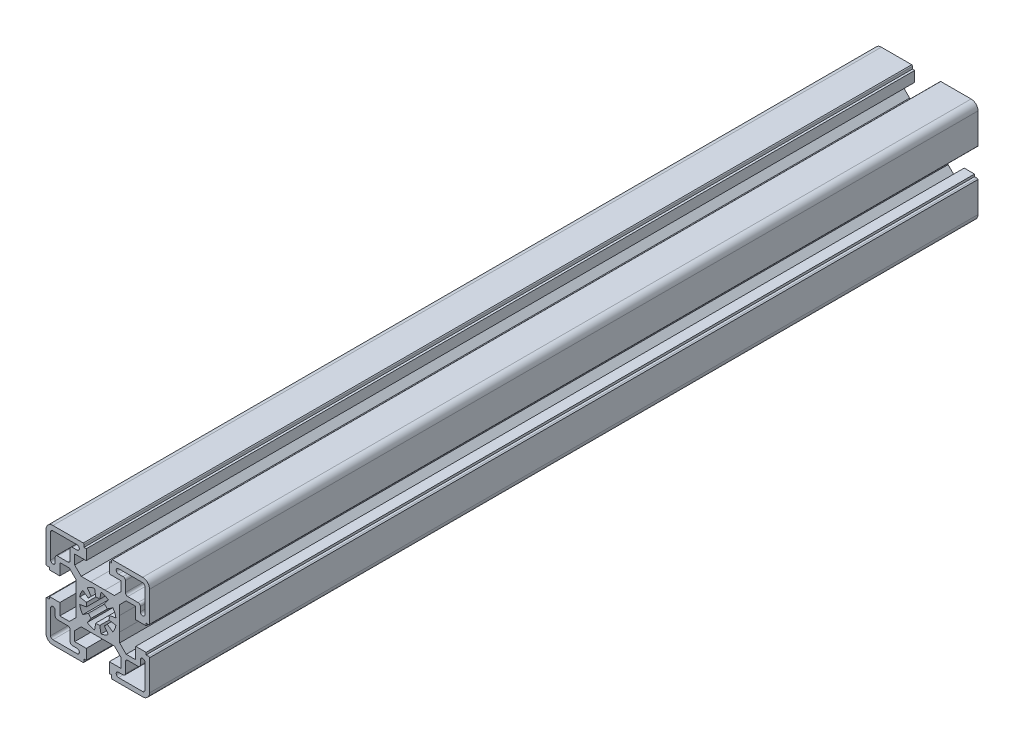
from build123d import *

# Parameters (mm, degrees)
BOSS_EXTRUDE1_DEPTH = 360


with BuildPart() as part:
    # Sketch1 → Boss-Extrude1 (new body)
    with BuildSketch(Plane.XY):
        with BuildLine():
            Line((-9.499953806, 3.122740916), (-9.499953806, 7.206970084))
            Line((-9.499953806, 7.206970084), (-12.342923806, 10.049940084))
            Line((-12.342923806, 10.049940084), (-16.500012806, 10.049940084))
            Line((-16.500012806, 10.049940084), (-16.500012806, 4.999940084))
            Line((-16.500012806, 4.999940084), (-20.999920806, 4.999940084))
            Line((-20.999920806, 4.999940084), (-20.999920806, 6))
            Line((-20.999920806, 6), (-21.99992119, 6))
            ThreePointArc((-21.99992119, 6), (-22.298164639, 6.069539801), (-22.49992067, 6.299929564))
            Line((-22.49992067, 6.299929564), (-22.49992067, 19.500002241))
            ThreePointArc((-22.49992067, 19.500002241), (-21.62124167, 21.621321), (-19.499922911, 22.5))
            Line((-19.499922911, 22.5), (-6.299954884, 22.5))
            ThreePointArc((-6.299954884, 22.5), (-6.069541349, 22.298205758), (-6, 21.999918456))
            Line((-6, 21.999918456), (-6, 20.999918083))
            Line((-6, 20.999918083), (-5, 20.999918083))
            Line((-5, 20.999918083), (-5, 16.499959846))
            Line((-5, 16.499959846), (-10.050086009, 16.499959846))
            Line((-10.050086009, 16.499959846), (-10.050086009, 12.342824291))
            Line((-10.050086009, 12.342824291), (-7.207137036, 9.499875319))
            Line((-7.207137036, 9.499875319), (-3.122784036, 9.499875319))
            Line((-3.122784036, 9.499875319), (3.122740916, 9.499953806))
            Line((3.122740916, 9.499953806), (7.206970084, 9.499953806))
            Line((7.206970084, 9.499953806), (10.049940084, 12.342923806))
            Line((10.049940084, 12.342923806), (10.049940084, 16.500012806))
            Line((10.049940084, 16.500012806), (4.999940084, 16.500012806))
            Line((4.999940084, 16.500012806), (4.999940084, 20.999920806))
            Line((4.999940084, 20.999920806), (6, 20.999920806))
            Line((6, 20.999920806), (6, 21.99992119))
            ThreePointArc((6, 21.99992119), (6.069539801, 22.298164639), (6.299929564, 22.49992067))
            Line((6.299929564, 22.49992067), (19.500002241, 22.49992067))
            ThreePointArc((19.500002241, 22.49992067), (21.621321, 21.62124167), (22.5, 19.499922911))
            Line((22.5, 19.499922911), (22.5, 6.299954884))
            ThreePointArc((22.5, 6.299954884), (22.298205758, 6.069541349), (21.999918456, 6))
            Line((21.999918456, 6), (20.999918083, 6))
            Line((20.999918083, 6), (20.999918083, 5))
            Line((20.999918083, 5), (16.499959846, 5))
            Line((16.499959846, 5), (16.499959846, 10.050086009))
            Line((16.499959846, 10.050086009), (12.342824291, 10.050086009))
            Line((12.342824291, 10.050086009), (9.499875319, 7.207137036))
            Line((9.499875319, 7.207137036), (9.499875319, 3.122784036))
            Line((9.499875319, 3.122784036), (9.499953806, -3.122740916))
            Line((9.499953806, -3.122740916), (9.499953806, -7.206970084))
            Line((9.499953806, -7.206970084), (12.342923806, -10.049940084))
            Line((12.342923806, -10.049940084), (16.500012806, -10.049940084))
            Line((16.500012806, -10.049940084), (16.500012806, -4.999940084))
            Line((16.500012806, -4.999940084), (20.999920806, -4.999940084))
            Line((20.999920806, -4.999940084), (20.999920806, -6))
            Line((20.999920806, -6), (21.99992119, -6))
            ThreePointArc((21.99992119, -6), (22.298164639, -6.069539801), (22.49992067, -6.299929564))
            Line((22.49992067, -6.299929564), (22.49992067, -19.500002241))
            ThreePointArc((22.49992067, -19.500002241), (21.62124167, -21.621321), (19.499922911, -22.5))
            Line((19.499922911, -22.5), (6.299954884, -22.5))
            ThreePointArc((6.299954884, -22.5), (6.069541349, -22.298205758), (6, -21.999918456))
            Line((6, -21.999918456), (6, -20.999918083))
            Line((6, -20.999918083), (5, -20.999918083))
            Line((5, -20.999918083), (5, -16.499959846))
            Line((5, -16.499959846), (10.050086009, -16.499959846))
            Line((10.050086009, -16.499959846), (10.050086009, -12.342824291))
            Line((10.050086009, -12.342824291), (7.207137036, -9.499875319))
            Line((7.207137036, -9.499875319), (3.122784036, -9.499875319))
            Line((3.122784036, -9.499875319), (-3.122740916, -9.499953806))
            Line((-3.122740916, -9.499953806), (-7.206970084, -9.499953806))
            Line((-7.206970084, -9.499953806), (-10.049940084, -12.342923806))
            Line((-10.049940084, -12.342923806), (-10.049940084, -16.500012806))
            Line((-10.049940084, -16.500012806), (-4.999940084, -16.500012806))
            Line((-4.999940084, -16.500012806), (-4.999940084, -20.999920806))
            Line((-4.999940084, -20.999920806), (-6, -20.999920806))
            Line((-6, -20.999920806), (-6, -21.99992119))
            ThreePointArc((-6, -21.99992119), (-6.069539801, -22.298164639), (-6.299929564, -22.49992067))
            Line((-6.299929564, -22.49992067), (-19.500002241, -22.49992067))
            ThreePointArc((-19.500002241, -22.49992067), (-21.621321, -21.62124167), (-22.5, -19.499922911))
            Line((-22.5, -19.499922911), (-22.5, -6.299954884))
            ThreePointArc((-22.5, -6.299954884), (-22.298205758, -6.069541349), (-21.999918456, -6))
            Line((-21.999918456, -6), (-20.999918083, -6))
            Line((-20.999918083, -6), (-20.999918083, -5))
            Line((-20.999918083, -5), (-16.499959846, -5))
            Line((-16.499959846, -5), (-16.499959846, -10.050086009))
            Line((-16.499959846, -10.050086009), (-12.342824291, -10.050086009))
            Line((-12.342824291, -10.050086009), (-9.499875319, -7.207137036))
            Line((-9.499875319, -7.207137036), (-9.499875319, -3.122784036))
            Line((-9.499875319, -3.122784036), (-9.499953806, 3.122740916))
        make_face()
        with BuildLine():
            Line((-4.588627311, 6.553189057), (-2.867885877, 4.095734317))
            ThreePointArc((-2.867885877, 4.095734317), (-3.535525782, 3.535515019), (-4.095743048, 2.867873408))
            Line((-4.095743048, 2.867873408), (-6.553203027, 4.588607361))
            ThreePointArc((-6.553203027, 4.588607361), (-7.391023494, 3.061463561), (-7.878449234, 1.389181447))
            Line((-7.878449234, 1.389181447), (-4.924020139, 0.868236529))
            ThreePointArc((-4.924020139, 0.868236529), (-4.9999809, 6.442e-06), (-4.924022376, -0.868223842))
            Line((-4.924022376, -0.868223842), (-7.878452813, -1.389161146))
            ThreePointArc((-7.878452813, -1.389161146), (-7.391022778, -3.061465289), (-6.553189057, -4.588627311))
            Line((-6.553189057, -4.588627311), (-4.095734317, -2.867885877))
            ThreePointArc((-4.095734317, -2.867885877), (-3.535515019, -3.535525782), (-2.867873408, -4.095743048))
            Line((-2.867873408, -4.095743048), (-4.588607361, -6.553203027))
            ThreePointArc((-4.588607361, -6.553203027), (-3.061463561, -7.391023494), (-1.389181447, -7.878449234))
            Line((-1.389181447, -7.878449234), (-0.868236529, -4.924020139))
            ThreePointArc((-0.868236529, -4.924020139), (-6.442e-06, -4.9999809), (0.868223842, -4.924022376))
            Line((0.868223842, -4.924022376), (1.389161146, -7.878452813))
            ThreePointArc((1.389161146, -7.878452813), (3.061465289, -7.391022778), (4.588627311, -6.553189057))
            Line((4.588627311, -6.553189057), (2.867885877, -4.095734317))
            ThreePointArc((2.867885877, -4.095734317), (3.535525782, -3.535515019), (4.095743048, -2.867873408))
            Line((4.095743048, -2.867873408), (6.553203027, -4.588607361))
            ThreePointArc((6.553203027, -4.588607361), (7.391023494, -3.061463561), (7.878449234, -1.389181447))
            Line((7.878449234, -1.389181447), (4.924020139, -0.868236529))
            ThreePointArc((4.924020139, -0.868236529), (4.9999809, -6.442e-06), (4.924022376, 0.868223842))
            Line((4.924022376, 0.868223842), (7.878452813, 1.389161146))
            ThreePointArc((7.878452813, 1.389161146), (7.391022778, 3.061465289), (6.553189057, 4.588627311))
            Line((6.553189057, 4.588627311), (4.095734317, 2.867885877))
            ThreePointArc((4.095734317, 2.867885877), (3.535515019, 3.535525782), (2.867873408, 4.095743048))
            Line((2.867873408, 4.095743048), (4.588607361, 6.553203027))
            ThreePointArc((4.588607361, 6.553203027), (3.061463561, 7.391023494), (1.389181447, 7.878449234))
            Line((1.389181447, 7.878449234), (0.868236529, 4.924020139))
            ThreePointArc((0.868236529, 4.924020139), (6.442e-06, 4.9999809), (-0.868223842, 4.924022376))
            Line((-0.868223842, 4.924022376), (-1.389161146, 7.878452813))
            ThreePointArc((-1.389161146, 7.878452813), (-3.061465289, 7.391022778), (-4.588627311, 6.553189057))
        make_face(mode=Mode.SUBTRACT)
        with BuildLine():
            Line((-17.500118733, 12.000017917), (-13.000117238, 12.000017917))
            ThreePointArc((-13.000117238, 12.000017917), (-12.293010986, 12.292910917), (-12.000117986, 13.00001717))
            Line((-12.000117986, 13.00001717), (-12.000117986, 17.49992083))
            ThreePointArc((-12.000117986, 17.49992083), (-11.707224986, 18.207027083), (-11.000118733, 18.499920083))
            Line((-11.000118733, 18.499920083), (-9.000117986, 18.499920083))
            ThreePointArc((-9.000117986, 18.499920083), (-8.000069069, 19.499969), (-9.000117986, 20.500017917))
            Line((-9.000117986, 20.500017917), (-19.500118733, 20.500017917))
            ThreePointArc((-19.500118733, 20.500017917), (-20.207224985, 20.207124917), (-20.500117986, 19.500018664))
            Line((-20.500117986, 19.500018664), (-20.500117986, 8.999920083))
            ThreePointArc((-20.500117986, 8.999920083), (-19.500117986, 7.999920083), (-18.500117985, 8.999920083))
            Line((-18.500117985, 8.999920083), (-18.500117985, 11.000018664))
            ThreePointArc((-18.500117985, 11.000018664), (-18.207224985, 11.707124917), (-17.500118733, 12.000017917))
        make_face(mode=Mode.SUBTRACT)
        with BuildLine():
            Line((12.000017917, 17.500118733), (12.000017917, 13.000117238))
            ThreePointArc((12.000017917, 13.000117238), (12.292910917, 12.293010986), (13.00001717, 12.000117986))
            Line((13.00001717, 12.000117986), (17.49992083, 12.000117986))
            ThreePointArc((17.49992083, 12.000117986), (18.207027083, 11.707224986), (18.499920083, 11.000118733))
            Line((18.499920083, 11.000118733), (18.499920083, 9.000117986))
            ThreePointArc((18.499920083, 9.000117986), (19.499969, 8.000069069), (20.500017917, 9.000117986))
            Line((20.500017917, 9.000117986), (20.500017917, 19.500118733))
            ThreePointArc((20.500017917, 19.500118733), (20.207124917, 20.207224985), (19.500018664, 20.500117985))
            Line((19.500018664, 20.500117985), (8.999920083, 20.500117985))
            ThreePointArc((8.999920083, 20.500117985), (7.999920083, 19.500117985), (8.999920083, 18.500117985))
            Line((8.999920083, 18.500117985), (11.000018664, 18.500117985))
            ThreePointArc((11.000018664, 18.500117985), (11.707124917, 18.207224985), (12.000017917, 17.500118733))
        make_face(mode=Mode.SUBTRACT)
        with BuildLine():
            Line((17.500118733, -12.000017917), (13.000117238, -12.000017917))
            ThreePointArc((13.000117238, -12.000017917), (12.293010986, -12.292910917), (12.000117986, -13.00001717))
            Line((12.000117986, -13.00001717), (12.000117986, -17.49992083))
            ThreePointArc((12.000117986, -17.49992083), (11.707224986, -18.207027083), (11.000118733, -18.499920083))
            Line((11.000118733, -18.499920083), (9.000117986, -18.499920083))
            ThreePointArc((9.000117986, -18.499920083), (8.000069069, -19.499969), (9.000117986, -20.500017917))
            Line((9.000117986, -20.500017917), (19.500118733, -20.500017917))
            ThreePointArc((19.500118733, -20.500017917), (20.207224985, -20.207124917), (20.500117985, -19.500018664))
            Line((20.500117985, -19.500018664), (20.500117985, -8.999920083))
            ThreePointArc((20.500117985, -8.999920083), (19.500117985, -7.999920083), (18.500117985, -8.999920083))
            Line((18.500117985, -8.999920083), (18.500117985, -11.000018664))
            ThreePointArc((18.500117985, -11.000018664), (18.207224985, -11.707124917), (17.500118733, -12.000017917))
        make_face(mode=Mode.SUBTRACT)
        with BuildLine():
            Line((-12.000017917, -17.500118733), (-12.000017917, -13.000117238))
            ThreePointArc((-12.000017917, -13.000117238), (-12.292910917, -12.293010986), (-13.00001717, -12.000117986))
            Line((-13.00001717, -12.000117986), (-17.49992083, -12.000117986))
            ThreePointArc((-17.49992083, -12.000117986), (-18.207027083, -11.707224986), (-18.499920083, -11.000118733))
            Line((-18.499920083, -11.000118733), (-18.499920083, -9.000117986))
            ThreePointArc((-18.499920083, -9.000117986), (-19.499969, -8.000069069), (-20.500017917, -9.000117986))
            Line((-20.500017917, -9.000117986), (-20.500017917, -19.500118733))
            ThreePointArc((-20.500017917, -19.500118733), (-20.207124917, -20.207224985), (-19.500018664, -20.500117985))
            Line((-19.500018664, -20.500117985), (-8.999920083, -20.500117985))
            ThreePointArc((-8.999920083, -20.500117985), (-7.999920083, -19.500117985), (-8.999920083, -18.500117985))
            Line((-8.999920083, -18.500117985), (-11.000018664, -18.500117985))
            ThreePointArc((-11.000018664, -18.500117985), (-11.707124917, -18.207224985), (-12.000017917, -17.500118733))
        make_face(mode=Mode.SUBTRACT)
    extrude(amount=BOSS_EXTRUDE1_DEPTH)


solid = part.part
